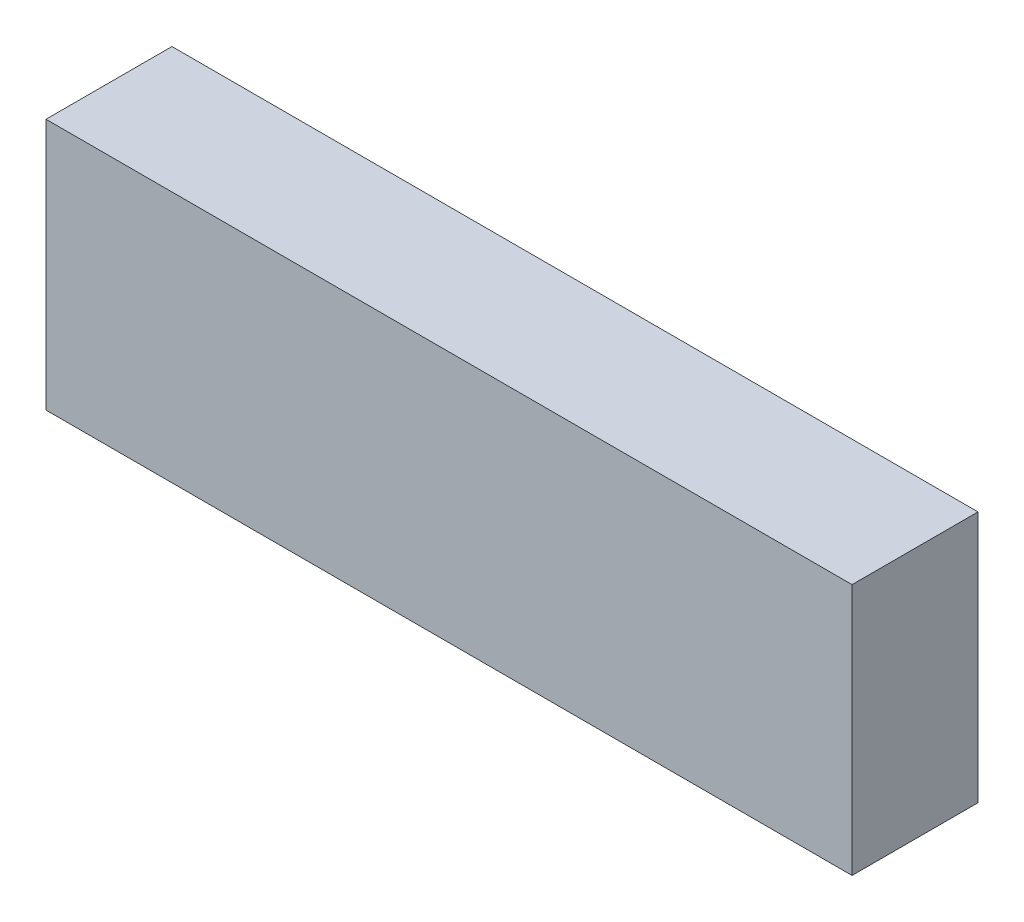
from build123d import *

# Parameters (mm, degrees)
ESQUISSE1_W        = 160
ESQUISSE1_H        = 50
BOSS_EXTRU_1_DEPTH = 25


with BuildPart() as part:
    # Esquisse1 → Boss.-Extru.1 (new body)
    with BuildSketch(Plane.XY):
        with Locations((80, 25)):
            Rectangle(ESQUISSE1_W, ESQUISSE1_H)
    extrude(amount=BOSS_EXTRU_1_DEPTH)


solid = part.part
